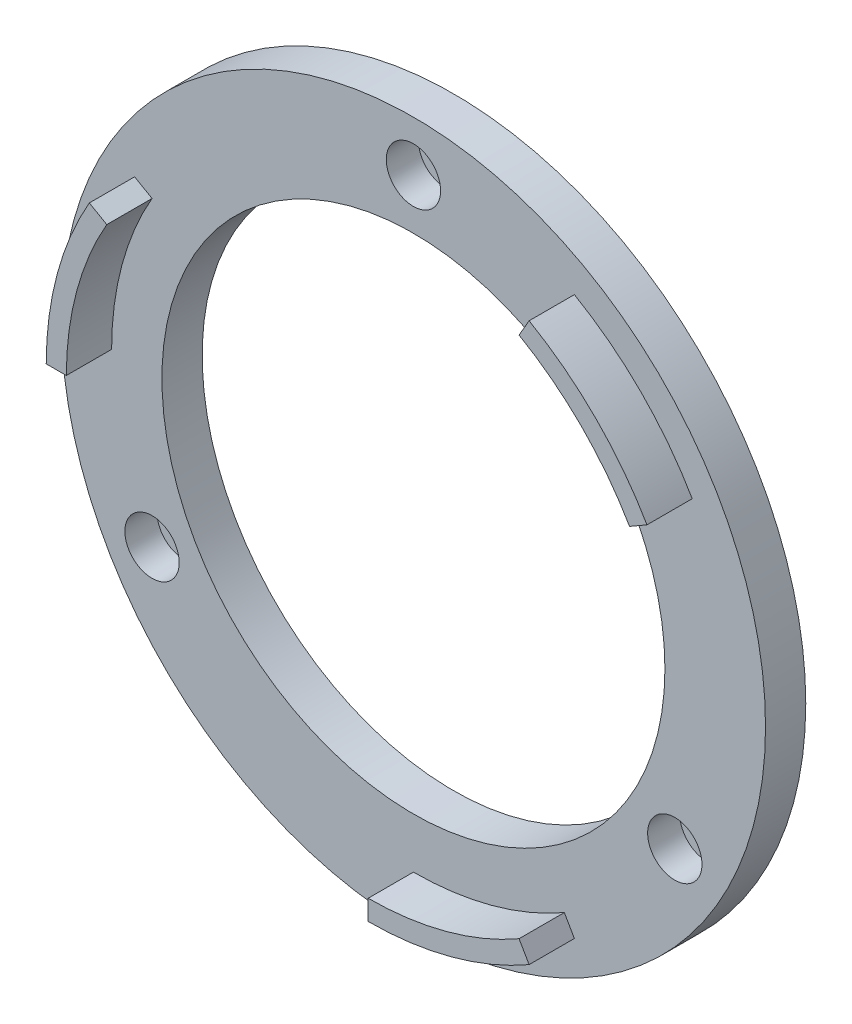
from build123d import *

# Parameters (mm, degrees)
SKETCH1_R           = 35
SKETCH1_R_2         = 30
SKETCH1_R_3         = 25
BOSS_EXTRUDE1_DEPTH = 4
SKETCH2_R           = 3.9
BOSS_EXTRUDE2_DEPTH = 7.1
SKETCH3_R           = 1.6
CUT_EXTRUDE1_DEPTH  = 15
SKETCH4_R           = 2.7
CUT_EXTRUDE2_DEPTH  = 3.2
BOSS_EXTRUDE3_DEPTH = 4.5
BOSS_EXTRUDE4_DEPTH = 4.5
SKETCH8_R           = 3.9
CUT_EXTRUDE3_DEPTH  = 12.5


with BuildPart() as part:
    # Sketch1 → Boss-Extrude1 (new body)
    with BuildSketch(Plane.XY):
        Circle(SKETCH1_R)
        Circle(SKETCH1_R_2, mode=Mode.SUBTRACT)
        Circle(SKETCH1_R_2)
        Circle(SKETCH1_R_3, mode=Mode.SUBTRACT)
    extrude(amount=BOSS_EXTRUDE1_DEPTH)

    # Sketch2 → Boss-Extrude2 (add)
    with BuildSketch(Plane(origin=(0, 0, 0), x_dir=(-1, 0, 0), z_dir=(0, 0, -1))):
        with Locations((0, 30)):
            Circle(SKETCH2_R)
        with Locations((25.980762114, -15)):
            Circle(SKETCH2_R)
        with Locations((-25.980762114, -15)):
            Circle(SKETCH2_R)
    extrude(amount=BOSS_EXTRUDE2_DEPTH)

    # Sketch3 → Cut-Extrude1 (cut)
    with BuildSketch(Plane(origin=(0, 0, -7.1), x_dir=(-1, 0, 0), z_dir=(0, 0, -1))):
        with Locations((0, 30)):
            Circle(SKETCH3_R)
        with Locations((25.980762114, -15)):
            Circle(SKETCH3_R)
        with Locations((-25.980762114, -15)):
            Circle(SKETCH3_R)
    extrude(amount=-CUT_EXTRUDE1_DEPTH, mode=Mode.SUBTRACT)

    # Sketch4 → Cut-Extrude2 (cut)
    with BuildSketch(Plane.XY.offset(4)):
        with Locations((0, 30)):
            Circle(SKETCH4_R)
        with Locations((25.980762114, -15)):
            Circle(SKETCH4_R)
        with Locations((-25.980762114, -15)):
            Circle(SKETCH4_R)
    extrude(amount=-CUT_EXTRUDE2_DEPTH, mode=Mode.SUBTRACT)

    # Sketch6 → Boss-Extrude3 (add)
    with BuildSketch(Plane.XY.offset(4)):
        with BuildLine():
            Line((25.980762114, 15), (27.712812921, 16))
            ThreePointArc((27.712812921, 16), (22.627416998, 22.627416998), (16, 27.712812921))
            Line((16, 27.712812921), (15, 25.980762114))
            ThreePointArc((15, 25.980762114), (21.213203436, 21.213203436), (25.980762114, 15))
        make_face()
    extrude(amount=BOSS_EXTRUDE3_DEPTH)

    # Sketch7 → Boss-Extrude4 (add)
    with BuildSketch(Plane.XY.offset(4)):
        with BuildLine():
            Line((16, -27.712812921), (15, -25.980762114))
            ThreePointArc((15, -25.980762114), (7.764571353, -28.977774789), (0, -30))
            Line((0, -30), (0, -32))
            ThreePointArc((0, -32), (8.282209443, -30.909626441), (16, -27.712812921))
        make_face()
        with BuildLine():
            Line((25.980762114, 15), (27.712812921, 16))
            ThreePointArc((27.712812921, 16), (22.627416998, 22.627416998), (16, 27.712812921))
            Line((16, 27.712812921), (15, 25.980762114))
            ThreePointArc((15, 25.980762114), (21.213203436, 21.213203436), (25.980762114, 15))
        make_face()
        with BuildLine():
            Line((-32, 0), (-30, 0))
            ThreePointArc((-30, 0), (-28.977774789, 7.764571353), (-25.980762114, 15))
            Line((-25.980762114, 15), (-27.712812921, 16))
            ThreePointArc((-27.712812921, 16), (-30.909626441, 8.282209443), (-32, 0))
        make_face()
    extrude(amount=BOSS_EXTRUDE4_DEPTH)

    # Sketch8 → Cut-Extrude3 (cut)
    with BuildSketch(Plane(origin=(0, 0, 0), x_dir=(-1, 0, 0), z_dir=(0, 0, -1))):
        with Locations((0, 30)):
            Circle(SKETCH8_R)
        with Locations((25.980762114, -15)):
            Circle(SKETCH8_R)
        with Locations((-25.980762114, -15)):
            Circle(SKETCH8_R)
    extrude(amount=CUT_EXTRUDE3_DEPTH, mode=Mode.SUBTRACT)


solid = part.part
